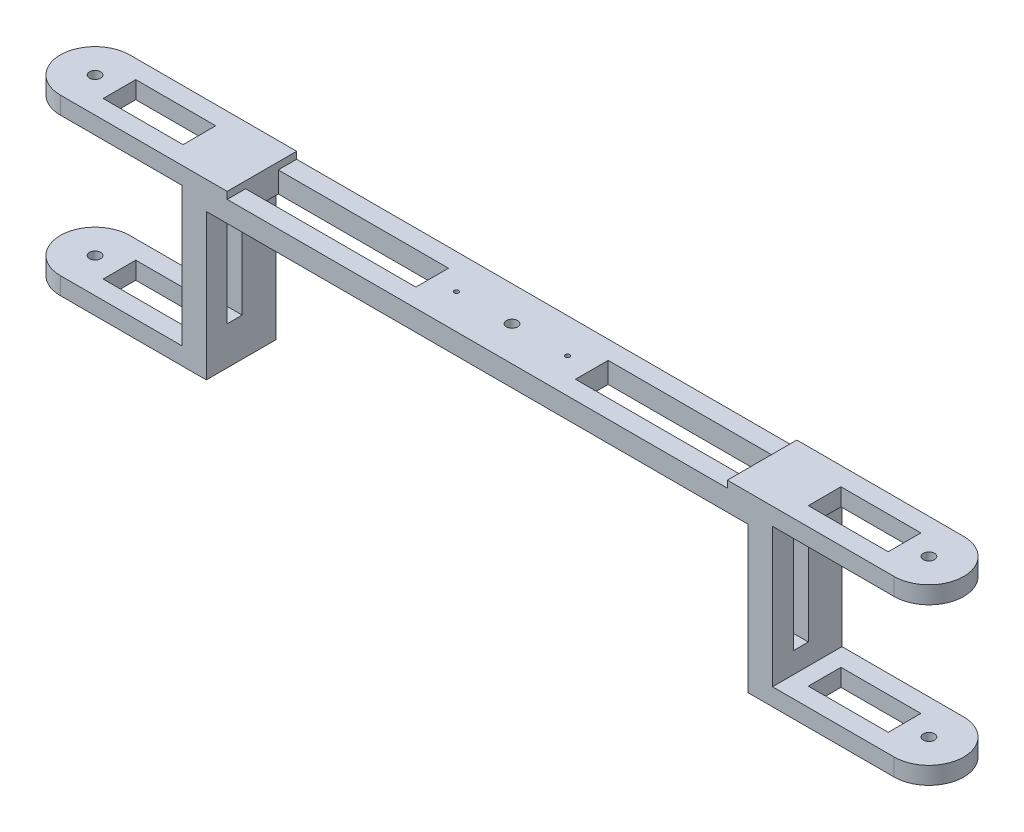
from build123d import *

# Parameters (mm, degrees)
SKETCH_1_R          = 1.6
SKETCH_1_R_2        = 0.64
EXTRUDE_1_DEPTH     = 50
SKETCH_4_W          = 155.949110162
SKETCH_4_H          = 42
CUT_EXTRUDE_3_DEPTH = 21
SKETCH_5_W          = 23
SKETCH_5_H          = 9.401567806
SKETCH_5_W_2        = 49
CUT_EXTRUDE_4_DEPTH = 51
SKETCH_6_W          = 4.324691993
SKETCH_6_H          = 28
CUT_EXTRUDE_5_DEPTH = 215.974555081
SKETCH_7_W          = 143.949110162
SKETCH_7_H          = 2
CUT_EXTRUDE_6_DEPTH = 21


with BuildPart() as part:
    # 草图1 → 凸台-拉伸1 (new body)
    with BuildSketch(Plane(origin=(0, 0, 0), x_dir=(1, 0, 0), z_dir=(0, 1, 0))):
        with BuildLine():
            Line((-163.25203252, 10), (76.74796748, 10))
            ThreePointArc((76.74796748, 10), (86.74796748, 0), (76.74796748, -10))
            Line((76.74796748, -10), (-163.25203252, -10))
            ThreePointArc((-163.25203252, -10), (-173.25203252, 0), (-163.25203252, 10))
        make_face()
        with Locations((76.74796748, 0)):
            Circle(SKETCH_1_R, mode=Mode.SUBTRACT)
        with Locations((-163.25203252, 0)):
            Circle(SKETCH_1_R, mode=Mode.SUBTRACT)
        with Locations((-59.25203252, 0)):
            Circle(SKETCH_1_R_2, mode=Mode.SUBTRACT)
        with Locations((-43.25203252, 0)):
            Circle(SKETCH_1_R, mode=Mode.SUBTRACT)
        with Locations((-27.25203252, 0)):
            Circle(SKETCH_1_R_2, mode=Mode.SUBTRACT)
    extrude(amount=EXTRUDE_1_DEPTH)

    # 草图4 → 切除-拉伸3 (cut, through all)
    with BuildSketch(Plane(origin=(0, 0, -10), x_dir=(-1, 0, 0), z_dir=(0, 0, -1))):
        Polygon((-86.722522561, 45), (-56.74796748, 45), (-41.722522561, 45), (-41.722522561, 5), (-56.74796748, 5), (-86.74796748, 5), (-94.689865515, 5), (-94.689865515, 45), align=None)
        Polygon((128.226587601, 5), (173.25203252, 5), (178.626350661, 5), (178.626350661, 45), (173.226587601, 45), (128.226587601, 45), align=None)
        with Locations((43.25203252, 21)):
            Rectangle(SKETCH_4_W, SKETCH_4_H)
    extrude(amount=-CUT_EXTRUDE_3_DEPTH, mode=Mode.SUBTRACT)

    # 草图5 → 切除-拉伸4 (cut, through all)
    with BuildSketch(Plane.XZ):
        with Locations((58.222522561, 0)):
            Rectangle(SKETCH_5_W, SKETCH_5_H)
        with Locations((4.222522561, 0)):
            Rectangle(SKETCH_5_W_2, SKETCH_5_H)
        with Locations((-90.726587601, 0)):
            Rectangle(SKETCH_5_W_2, SKETCH_5_H)
        with Locations((-144.726587601, 0)):
            Rectangle(SKETCH_5_W, SKETCH_5_H)
    extrude(amount=-CUT_EXTRUDE_4_DEPTH, mode=Mode.SUBTRACT)

    # 草图6 → 切除-拉伸5 (cut, through all)
    with BuildSketch(Plane.ZY.offset(128.226587601)):
        with Locations((1.837654003, 25)):
            Rectangle(SKETCH_6_W, SKETCH_6_H)
    extrude(amount=-CUT_EXTRUDE_5_DEPTH, mode=Mode.SUBTRACT)

    # 草图7 → 切除-拉伸6 (cut, through all)
    with BuildSketch(Plane.XY.offset(10)):
        with Locations((-43.25203252, 49)):
            Rectangle(SKETCH_7_W, SKETCH_7_H)
    extrude(amount=-CUT_EXTRUDE_6_DEPTH, mode=Mode.SUBTRACT)


solid = part.part
